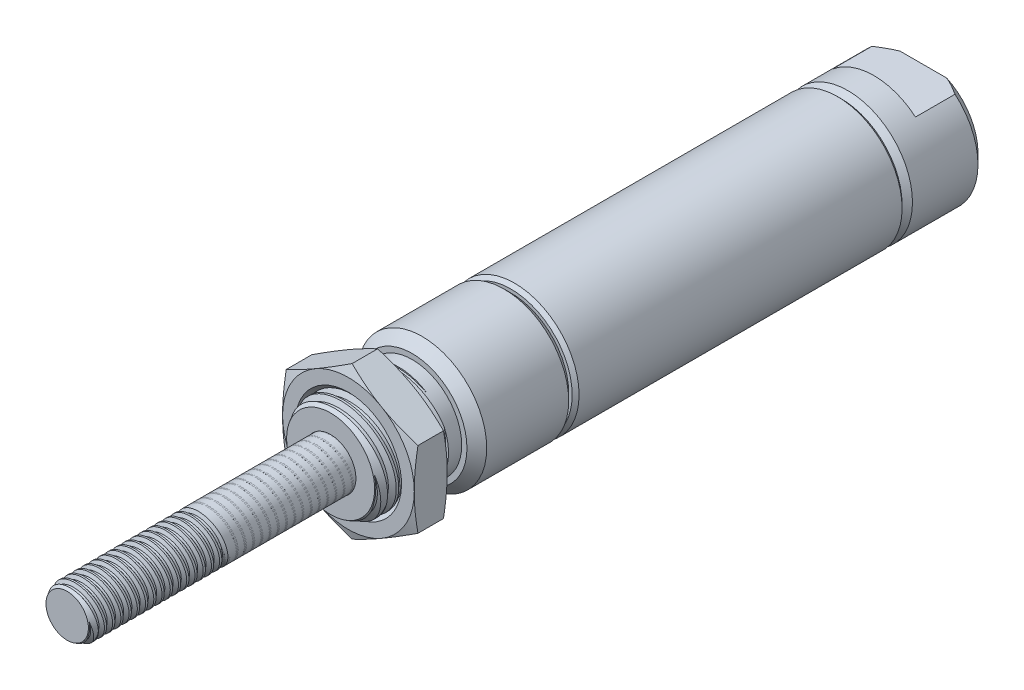
from build123d import *

# Parameters (mm, degrees)
SKETCH1_W               = 49.276
SKETCH1_H               = 6.223
CUT_EXTRUDE1_DEPTH      = 37.01676114
CUT_EXTRUDE1_DEPTH_BACK = 37.01676114
SKETCH2_W               = 4.7625
SKETCH2_H               = 1.4605
CHAMFER1_SIZE           = 0.9525
SKETCH4_W               = 7.874
SKETCH4_H               = 4.7625
LPATTERN2_COUNT         = 2
LPATTERN2_PITCH         = 1.058333333
LPATTERN2_COUNT_DIR2    = 7
LPATTERN2_PITCH_DIR2    = 1.058333333
SKETCH53_W              = 1.27
SKETCH53_H              = 4.7625
LPATTERN3_COUNT         = 2
LPATTERN3_PITCH         = 0.79375
LPATTERN3_COUNT_DIR2    = 16
LPATTERN3_PITCH_DIR2    = 0.79375
LPATTERN4_COUNT         = 2
LPATTERN4_PITCH         = 12.7
SKETCH52_W              = 4.191
SKETCH52_H              = 1.034648084
SKETCH54_R              = 4.7625
EXTRUDE1_DEPTH          = 1.5875


with BuildPart() as part:
    # Sketch1 → Revolve1 (revolve)
    with BuildSketch(Plane(origin=(0, 0, 0), x_dir=(0, 0, -1), z_dir=(1, 0, 0))):
        with Locations((10.287, 3.1115)):
            Rectangle(SKETCH1_W, SKETCH1_H)
    revolve(axis=Axis((0, 0, -34.925), (0, 0, -1)))

    # Sketch2 → Cut-Extrude1 (cut, two sides: drawn at the far end of the back side and taken through both)
    with BuildSketch(Plane(origin=(0, 0, 0), x_dir=(0, 0, -1), z_dir=(1, 0, 0)).offset(-CUT_EXTRUDE1_DEPTH_BACK)):
        with Locations((32.54375, 5.49275)):
            Rectangle(SKETCH2_W, SKETCH2_H)
        with Locations((32.54375, -5.49275)):
            Rectangle(SKETCH2_W, SKETCH2_H)
    extrude(amount=CUT_EXTRUDE1_DEPTH + CUT_EXTRUDE1_DEPTH_BACK, mode=Mode.SUBTRACT)

    # Chamfer1
    chamfer1_edges = [part.edges().sort_by_distance(p)[0] for p in [
        (-6.223, 0, -34.925),
        (6.223, 0, -34.925),
        (0, -6.223, 14.351),
    ]]
    chamfer(chamfer1_edges, length=CHAMFER1_SIZE)



with BuildPart() as body_2:
    # Sketch4 → Revolve2 (revolve)
    with BuildSketch(Plane(origin=(0, 0, 0), x_dir=(0, 0, -1), z_dir=(1, 0, 0))):
        with Locations((-18.288, 2.38125)):
            Rectangle(SKETCH4_W, SKETCH4_H)
    revolve(axis=Axis((0, 0, 22.225), (0, 0, -1)))

    # Sketch5 → Cut-Revolve2 (revolve, cut)
    with BuildSketch(Plane(origin=(0, 0, 0), x_dir=(0, 0, -1), z_dir=(1, 0, 0))):
        Polygon((-22.093517464, 4.777109171), (-21.173139714, 4.879373365), (-21.438586489, 4.273514358), (-21.70155156, 4.244296017), align=None)
    cut_revolve2 = revolve(axis=Axis((0, -0.125349185, 22.225), (0, 0.11043152607484777, -0.9938837346736188)), mode=Mode.SUBTRACT)

    # Sketch6 → Cut-Revolve3 (revolve, cut)
    with BuildSketch(Plane(origin=(0, 0, 0), x_dir=(0, 0, -1), z_dir=(1, 0, 0))):
        Polygon((-22.225, 4.244296017), (-21.327444372, 4.7625), (-22.225, 4.7625), align=None)
    revolve(axis=Axis((0, 0, 0), (0, 0, 1)), mode=Mode.SUBTRACT)

    # LPattern2: Cut-Revolve2 2 × 7
    with Locations(*[Vector(0, 0, 1) * (i * LPATTERN2_PITCH) + Vector(0, 0, -1) * (j * LPATTERN2_PITCH_DIR2) for i in range(LPATTERN2_COUNT) for j in range(LPATTERN2_COUNT_DIR2) if (i, j) != (0, 0)]):
        add(cut_revolve2, mode=Mode.SUBTRACT)


with BuildPart() as part_1:
    add(part.part)

    add(body_2.part)  # Revolve4 merges body 2
    # Sketch53 → Revolve4 (revolve)
    with BuildSketch(Plane(origin=(0, 0, 0), x_dir=(0, 0, -1), z_dir=(1, 0, 0))):
        with Locations((-14.986, 2.38125)):
            Rectangle(SKETCH53_W, SKETCH53_H)
    revolve(axis=Axis((0, 0, 14.351), (0, 0, 1)))

    # Sketch7 → Cut-Revolve5 (revolve, cut)
    with BuildSketch(Plane(origin=(0, 0, 0), x_dir=(0, 0, -1), z_dir=(1, 0, 0))):
        Polygon((-22.225, 2.4384), (-11.176, 2.4384), (-11.176, 3.997325), (-1.651, 3.997325), (-1.651, 5.55625), (11.049, 5.55625), (23.749, 5.55625), (23.749, 0), (-22.225, 0), align=None)
    revolve(axis=Axis((0, 0, -23.749), (0, 0, -1)), mode=Mode.SUBTRACT)

    # Sketch3 → Cut-Revolve1 (revolve, cut)
    with BuildSketch(Plane(origin=(0, 0, 0), x_dir=(0, 0, -1), z_dir=(1, 0, 0))):
        Polygon((27.65425, 6.223), (26.9875, 5.55625), (26.9875, 5.889625), (26.654125, 6.223), align=None)
        Polygon((-4.826, 5.55625), (-5.49275, 6.223), (-4.492625, 6.223), (-4.826, 5.889625), align=None)
    revolve(axis=Axis((0, 0, -34.925), (0, 0, -1)), mode=Mode.SUBTRACT)

    # Sketch13 → Cut-Revolve22 (revolve, cut)
    with BuildSketch(Plane(origin=(0, -1.751719437, 219.449698312), x_dir=(0, 0, -1), z_dir=(1, 0, 0))):
        Polygon((247.389698312, 1.751719437), (247.389698312, 3.821015605), (247.40482128, 3.847209355), (247.771450343, 4.48222952), (247.80169628, 4.48222952), (248.168325343, 3.847209355), (248.19857128, 3.847209355), (248.565200343, 4.48222952), (248.59544628, 4.48222952), (248.962075343, 3.847209355), (248.99232128, 3.847209355), (249.358950343, 4.48222952), (249.38919628, 4.48222952), (249.755825343, 3.847209355), (249.78607128, 3.847209355), (250.152700343, 4.48222952), (250.18294628, 4.48222952), (250.549575343, 3.847209355), (250.57982128, 3.847209355), (250.946450343, 4.48222952), (250.97669628, 4.48222952), (251.343325343, 3.847209355), (251.37357128, 3.847209355), (251.740200343, 4.48222952), (251.77044628, 4.48222952), (252.137075343, 3.847209355), (252.16732128, 3.847209355), (252.533950343, 4.48222952), (252.56419628, 4.48222952), (252.930825343, 3.847209355), (252.96107128, 3.847209355), (253.327700343, 4.48222952), (253.35794628, 4.48222952), (253.724575343, 3.847209355), (253.75482128, 3.847209355), (254.121450343, 4.48222952), (254.15169628, 4.48222952), (254.518325343, 3.847209355), (254.54857128, 3.847209355), (254.915200343, 4.48222952), (254.94544628, 4.48222952), (255.312075343, 3.847209355), (255.34232128, 3.847209355), (255.708950343, 4.48222952), (255.73919628, 4.48222952), (256.105825343, 3.847209355), (256.13607128, 3.847209355), (256.502700343, 4.48222952), (256.53294628, 4.48222952), (256.899575343, 3.847209355), (256.92982128, 3.847209355), (257.296450343, 4.48222952), (257.32669628, 4.48222952), (257.693325343, 3.847209355), (257.72357128, 3.847209355), (258.090200343, 4.48222952), (258.12044628, 4.48222952), (258.487075343, 3.847209355), (258.51732128, 3.847209355), (258.883950343, 4.48222952), (258.91419628, 4.48222952), (259.280825343, 3.847209355), (259.31107128, 3.847209355), (259.31107128, 1.751719437), align=None)
    revolve(axis=Axis((0, 0, -27.94), (0, 0, 1)), mode=Mode.SUBTRACT)

    # Sketch52 → Cut-Revolve23 (revolve, cut)
    with BuildSketch(Plane(origin=(0, 0, 0), x_dir=(0, 0, -1), z_dir=(1, 0, 0))):
        with Locations((25.8445, 0.517324042)):
            Rectangle(SKETCH52_W, SKETCH52_H)
    revolve(axis=Axis((0, 0, -27.94), (0, 0, 1)), mode=Mode.SUBTRACT)


with BuildPart() as body_2_2:
    # Sketch8 → Revolve3 (revolve)
    with BuildSketch(Plane(origin=(0, 0, 0), x_dir=(0, 0, -1), z_dir=(1, 0, 0))):
        Polygon((11.049, 2.413), (11.049, 5.50545), (23.749, 5.50545), (23.749, 0), (-34.925, 0), (-34.925, 2.413), align=None)
    revolve(axis=Axis((0, 0, -23.749), (0, 0, 1)))

    # Sketch10 → Cut-Revolve6 (revolve, cut)
    with BuildSketch(Plane(origin=(0, 0, 0), x_dir=(0, 0, -1), z_dir=(1, 0, 0))):
        Polygon((-34.827096635, 2.429102527), (-34.141773076, 2.541820218), (-34.316805502, 2.077629892), (-34.512612233, 2.045424837), align=None)
    cut_revolve6 = revolve(axis=Axis((0, -0.139697061, 34.925), (0, 0.16229318767089784, -0.9867425810390564)), mode=Mode.SUBTRACT)

    # Sketch11 → Cut-Revolve7 (revolve, cut)
    with BuildSketch(Plane(origin=(0, 0, 0), x_dir=(0, 0, -1), z_dir=(1, 0, 0))):
        Polygon((-34.925, 2.413), (-34.288341142, 2.413), (-34.925, 2.045424837), align=None)
    revolve(axis=Axis((0, 0, 0), (0, 0, 1)), mode=Mode.SUBTRACT)

    # LPattern3: Cut-Revolve6 2 × 16
    with Locations(*[Vector(0, 0, 1) * (i * LPATTERN3_PITCH) + Vector(0, 0, -1) * (j * LPATTERN3_PITCH_DIR2) for i in range(LPATTERN3_COUNT) for j in range(LPATTERN3_COUNT_DIR2) if (i, j) != (0, 0)]):
        add(cut_revolve6, mode=Mode.SUBTRACT)


with BuildPart() as lpattern4_1:
    # LPattern4: pattern copy
    add(body_2_2.part.moved(Location(Vector(0, 0, 1) * (1 * LPATTERN4_PITCH))))


with BuildPart() as body_4:
    # Sketch54 → Extrude1 (new, symmetric)
    with BuildSketch(Plane.XY.offset(18.923)):
        Polygon((0, 7.332348419), (-6.35, 3.666174209), (-6.35, -3.666174209), (0, -7.332348419), (6.35, -3.666174209), (6.35, 3.666174209), align=None)
        Circle(SKETCH54_R, mode=Mode.SUBTRACT)
    extrude(amount=EXTRUDE1_DEPTH, both=True)

    # Sketch55 → Cut-Revolve24 (revolve, cut)
    with BuildSketch(Plane(origin=(0, 0, 0), x_dir=(0, 0, -1), z_dir=(1, 0, 0))):
        Polygon((-20.152954416, 7.332348419), (-20.5105, 7.332348419), (-20.5105, 6.35), align=None)
        Polygon((-17.693045584, 7.332348419), (-17.3355, 7.332348419), (-17.3355, 6.35), align=None)
        Polygon((-20.5105, 5.120045584), (-20.5105, 4.7625), (-20.152954416, 4.7625), align=None)
        Polygon((-17.3355, 5.120045584), (-17.3355, 4.7625), (-17.693045584, 4.7625), align=None)
    revolve(axis=Axis((0, 0, 0), (0, 0, 1)), mode=Mode.SUBTRACT)


solid = Compound([part_1.part, body_2_2.part, lpattern4_1.part, body_4.part])
